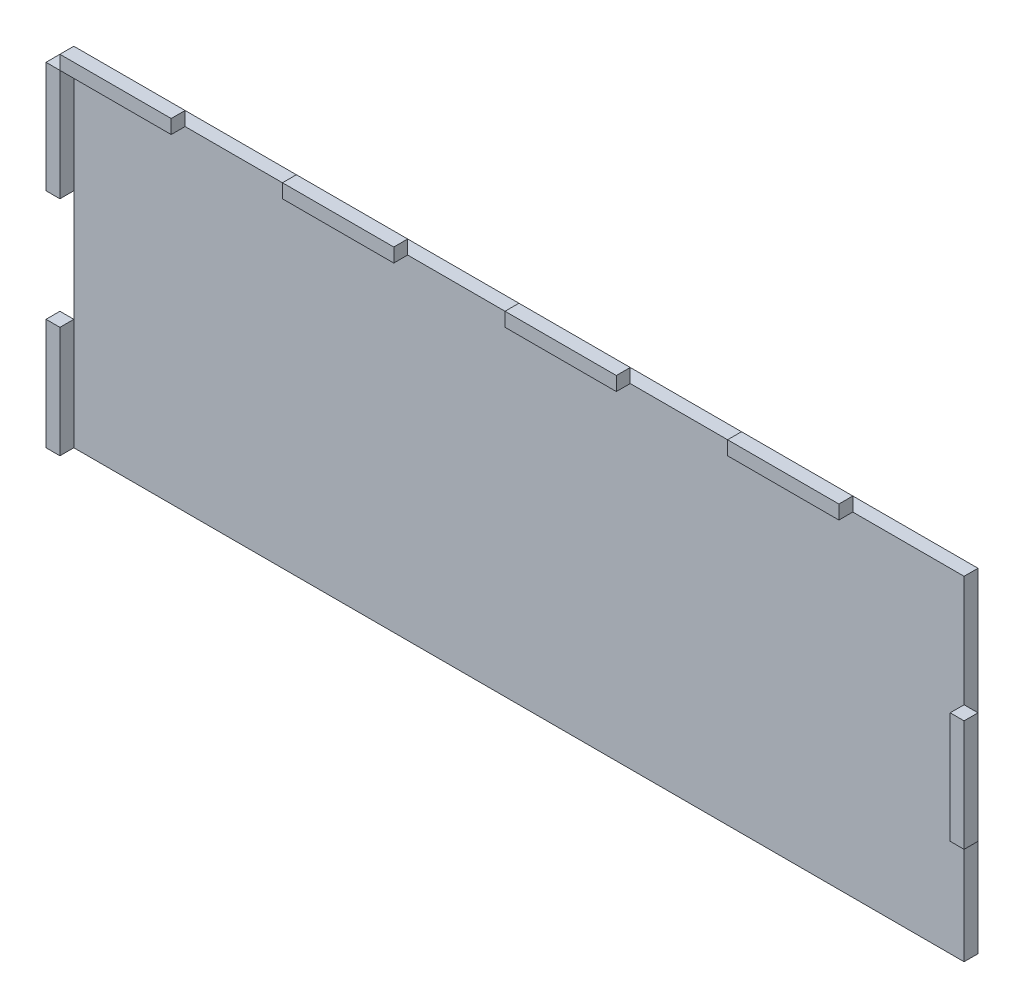
from build123d import *

# Parameters (mm, degrees)
SKETCH1_W             = 203.2
SKETCH1_H             = 76.2
BOSS_EXTRUDE1_DEPTH   = 3.175
SKETCH2_W             = 25.4
SKETCH2_H             = 3.175
BOSS_EXTRUDE2_DEPTH   = 3.175
BOSS_EXTRUDE2_2_DEPTH = 3.175
BOSS_EXTRUDE2_3_DEPTH = 3.175
BOSS_EXTRUDE2_4_DEPTH = 3.175
SKETCH4_W             = 3.175
SKETCH4_H             = 25.4
BOSS_EXTRUDE4_DEPTH   = 3.175
BOSS_EXTRUDE4_2_DEPTH = 3.175
SKETCH6_W             = 3.175
SKETCH6_H             = 25.4
BOSS_EXTRUDE6_DEPTH   = 3.175


with BuildPart() as part:
    # Sketch1 → Boss-Extrude1 (new body)
    with BuildSketch(Plane.XY):
        Rectangle(SKETCH1_W, SKETCH1_H)
    extrude(amount=BOSS_EXTRUDE1_DEPTH)


with BuildPart() as body_2:
    # Sketch2 → Boss-Extrude2 (new body)
    with BuildSketch(Plane.XY.offset(3.175)):
        with Locations((-38.1, 39.6875)):
            Rectangle(SKETCH2_W, SKETCH2_H)
    extrude(amount=BOSS_EXTRUDE2_DEPTH)


with BuildPart() as body_3:
    # Sketch2 → Boss-Extrude2 2 (new body)
    with BuildSketch(Plane.XY.offset(3.175)):
        with Locations((-88.9, 39.6875)):
            Rectangle(SKETCH2_W, SKETCH2_H)
    extrude(amount=BOSS_EXTRUDE2_2_DEPTH)


with BuildPart() as body_4:
    # Sketch2 → Boss-Extrude2 3 (new body)
    with BuildSketch(Plane.XY.offset(3.175)):
        with Locations((12.7, 39.6875)):
            Rectangle(SKETCH2_W, SKETCH2_H)
    extrude(amount=BOSS_EXTRUDE2_3_DEPTH)


with BuildPart() as body_5:
    # Sketch2 → Boss-Extrude2 4 (new body)
    with BuildSketch(Plane.XY.offset(3.175)):
        with Locations((63.5, 39.6875)):
            Rectangle(SKETCH2_W, SKETCH2_H)
    extrude(amount=BOSS_EXTRUDE2_4_DEPTH)


with BuildPart() as body_6:
    # Sketch4 → Boss-Extrude4 (new body)
    with BuildSketch(Plane.XY.offset(3.175)):
        with Locations((-103.1875, -25.4)):
            Rectangle(SKETCH4_W, SKETCH4_H)
    extrude(amount=BOSS_EXTRUDE4_DEPTH)


with BuildPart() as body_7:
    # Sketch4 → Boss-Extrude4 2 (new body)
    with BuildSketch(Plane.XY.offset(3.175)):
        with Locations((-103.1875, 25.4)):
            Rectangle(SKETCH4_W, SKETCH4_H)
    extrude(amount=BOSS_EXTRUDE4_2_DEPTH)


with BuildPart() as body_8:
    # Sketch6 → Boss-Extrude6 (new body)
    with BuildSketch(Plane.XY.offset(3.175)):
        with Locations((103.1875, 0)):
            Rectangle(SKETCH6_W, SKETCH6_H)
    extrude(amount=BOSS_EXTRUDE6_DEPTH)


solid = Compound([part.part, body_2.part, body_3.part, body_4.part, body_5.part, body_6.part, body_7.part, body_8.part])
